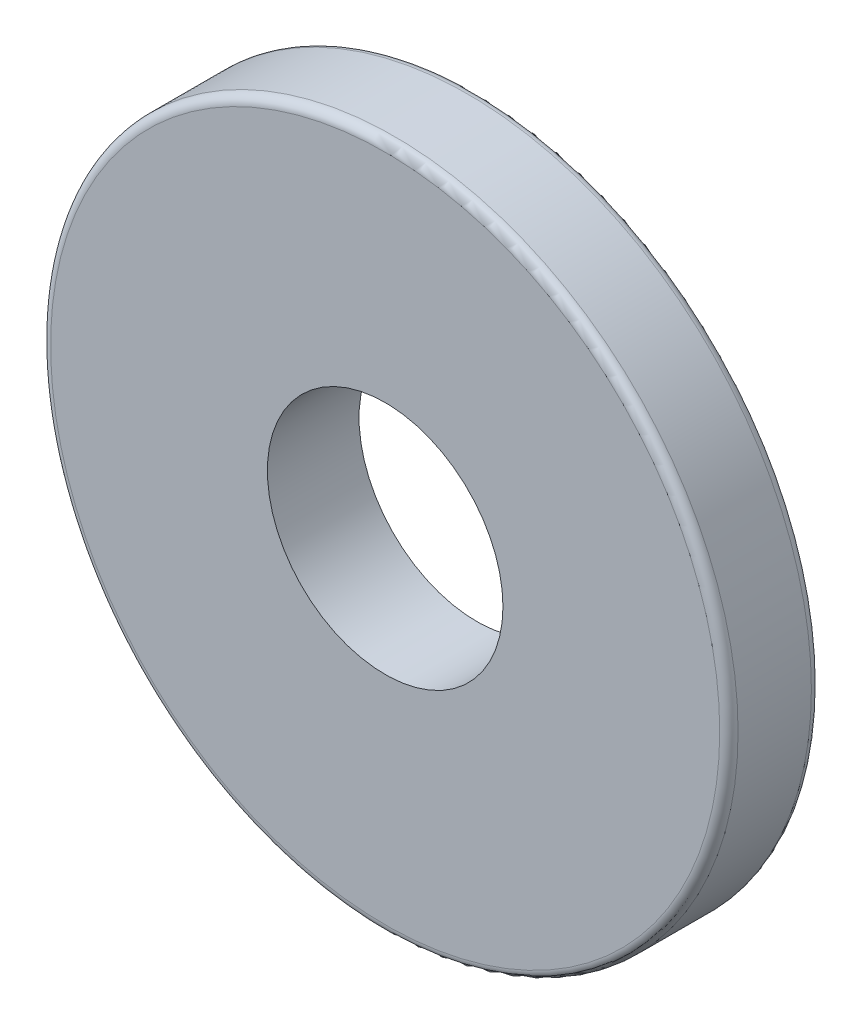
from build123d import *

# Parameters (mm, degrees)
SKETCH2_R           = 9.525
SKETCH2_R_2         = 3.2639
BOSS_EXTRUDE1_DEPTH = 2.54
FILLET1_R           = 0.254


with BuildPart() as part:
    # Sketch2 → Boss-Extrude1 (new body)
    with BuildSketch(Plane.XY):
        Circle(SKETCH2_R)
        Circle(SKETCH2_R_2, mode=Mode.SUBTRACT)
    extrude(amount=BOSS_EXTRUDE1_DEPTH)

    # Fillet1
    fillet1_edges = [part.edges().sort_by_distance(p)[0] for p in [
        (-9.525, 0, 0),
        (-9.525, 0, 2.54),
    ]]
    fillet(fillet1_edges, radius=FILLET1_R)


solid = part.part
